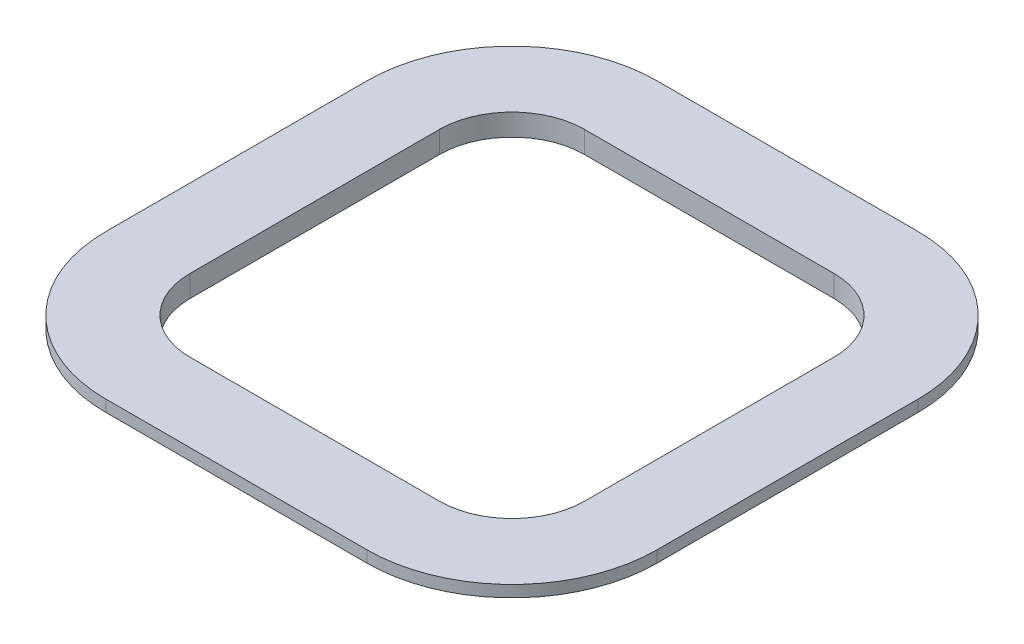
from build123d import *

# Parameters (mm, degrees)
SKETCH1_W      = 38
SKETCH1_H      = 38
SKETCH1_W_2    = 27.2
SKETCH1_H_2    = 27.2
EXTRUDE1_DEPTH = 1.5
FILLET1_R      = 5
FILLET2_R      = 10


with BuildPart() as part:
    # Sketch1 → Extrude1 (new body)
    with BuildSketch(Plane(origin=(0, 0, 0), x_dir=(1, 0, 0), z_dir=(0, 1, 0))):
        Rectangle(SKETCH1_W, SKETCH1_H)
        Rectangle(SKETCH1_W_2, SKETCH1_H_2, mode=Mode.SUBTRACT)
    extrude(amount=-EXTRUDE1_DEPTH)

    # Fillet1
    fillet1_edges = [part.edges().sort_by_distance(p)[0] for p in [
        (-13.6, -0.75, 13.6),
        (-13.6, -0.75, -13.6),
        (13.6, -0.75, -13.6),
        (13.6, -0.75, 13.6),
    ]]
    fillet(fillet1_edges, radius=FILLET1_R)

    # Fillet2
    fillet2_edges = [part.edges().sort_by_distance(p)[0] for p in [
        (-19, -0.75, -19),
        (19, -0.75, -19),
        (19, -0.75, 19),
        (-19, -0.75, 19),
    ]]
    fillet(fillet2_edges, radius=FILLET2_R)

    # Cut-Sweep1: sweep along a path in Sketch4
    with BuildLine(Plane.XZ.offset(1.5)) as cut_sweep1_path:
        Line((9, -19), (-9, -19))
        ThreePointArc((-9, -19), (-16.071067812, -16.071067812), (-19, -9))
        Line((-19, -9), (-19, 9))
        ThreePointArc((-19, 9), (-16.071067812, 16.071067812), (-9, 19))
        Line((-9, 19), (9, 19))
        ThreePointArc((9, 19), (16.071067812, 16.071067812), (19, 9))
        Line((19, 9), (19, -9))
        ThreePointArc((19, -9), (16.071067812, -16.071067812), (9, -19))
    # Sketch2 → Cut-Sweep1 (sweep, cut)
    with BuildSketch(Plane.XY):
        Polygon((19, -0.8), (19, -1.5), (13.6, -1.5), align=None)
    sweep(path=cut_sweep1_path.line, mode=Mode.SUBTRACT)


solid = part.part
